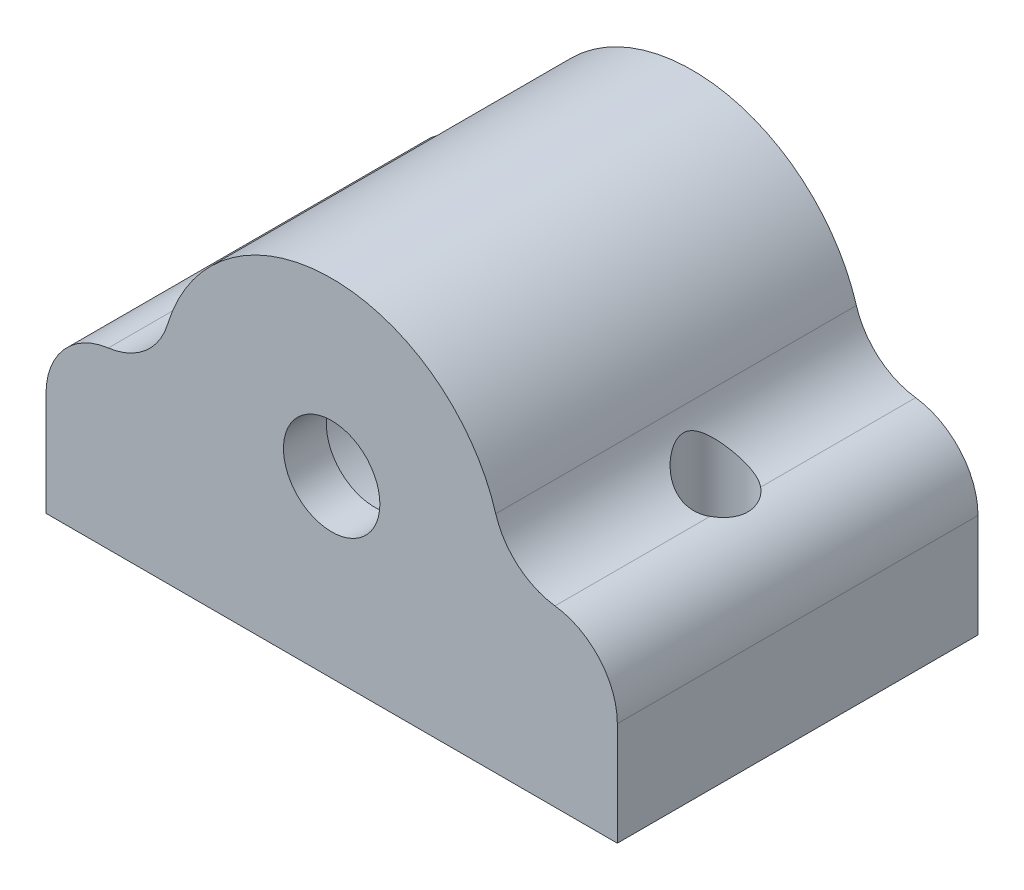
from build123d import *

# Parameters (mm, degrees)
SKETCH1_R               = 14
BOSS_EXTRUDE1_DEPTH     = 50.5
BOSS_EXTRUDE3_START     = -6
SKETCH5_R               = 14
SKETCH5_R_2             = 6.75
BOSS_EXTRUDE3_DEPTH     = 6
FILLET3_R               = 4
FILLET1_R               = 10
FILLET2_R               = 10
CUT_EXTRUDE1_DEPTH      = 50.5
CUT_EXTRUDE1_DEPTH_BACK = 50.5
SKETCH2_R               = 4.5
SKETCH4_W               = 80
SKETCH4_H               = 50.5
SKETCH4_R               = 2.05
BOSS_EXTRUDE2_DEPTH     = 5


with BuildPart() as part:
    # Sketch1 → Boss-Extrude1 (new body)
    with BuildSketch(Plane.XY):
        with BuildLine():
            Line((-40, 0), (-40, -24.5))
            Line((-40, -24.5), (40, -24.5))
            Line((40, -24.5), (40, 0))
            Line((40, 0), (24, 0))
            ThreePointArc((24, 0), (0, 24), (-24, 0))
            Line((-24, 0), (-40, 0))
        make_face()
        Circle(SKETCH1_R, mode=Mode.SUBTRACT)
    extrude(amount=BOSS_EXTRUDE1_DEPTH)

    # Sketch5 → Boss-Extrude3 (add)
    with BuildSketch(Plane.XY.offset(50.5).offset(BOSS_EXTRUDE3_START)):
        Circle(SKETCH5_R)
        Circle(SKETCH5_R_2, mode=Mode.SUBTRACT)
    extrude(amount=BOSS_EXTRUDE3_DEPTH)

    # Fillet3
    fillet3_edges = [part.edges().sort_by_distance(p)[0] for p in [
        (-14, 0, 44.5),
    ]]
    fillet(fillet3_edges, radius=FILLET3_R)

    # Fillet1
    fillet1_edges = [part.edges().sort_by_distance(p)[0] for p in [
        (40, 0, 25.25),
        (-40, 0, 25.25),
    ]]
    fillet(fillet1_edges, radius=FILLET1_R)

    # Fillet2
    fillet2_edges = [part.edges().sort_by_distance(p)[0] for p in [
        (-24, 0, 25.25),
        (24, 0, 25.25),
    ]]
    fillet(fillet2_edges, radius=FILLET2_R)

    # Sketch2 → Cut-Extrude1 (cut, two sides: drawn at the far end of the back side and taken through both)
    with BuildSketch(Plane(origin=(0, 0, 0), x_dir=(1, 0, 0), z_dir=(0, 1, 0)).offset(-CUT_EXTRUDE1_DEPTH_BACK)):
        with Locations((28.5, -25.25)):
            Circle(SKETCH2_R)
        with Locations((-28.5, -25.25)):
            Circle(SKETCH2_R)
    extrude(amount=CUT_EXTRUDE1_DEPTH + CUT_EXTRUDE1_DEPTH_BACK, mode=Mode.SUBTRACT)

    # Sketch4 → Boss-Extrude2 (add)
    with BuildSketch(Plane.XZ.offset(24.5)):
        with Locations((0, 25.25)):
            Rectangle(SKETCH4_W, SKETCH4_H)
        with Locations((-28.5, 25.25)):
            Circle(SKETCH4_R, mode=Mode.SUBTRACT)
        with Locations((28.5, 25.25)):
            Circle(SKETCH4_R, mode=Mode.SUBTRACT)
    extrude(amount=-BOSS_EXTRUDE2_DEPTH)


solid = part.part
